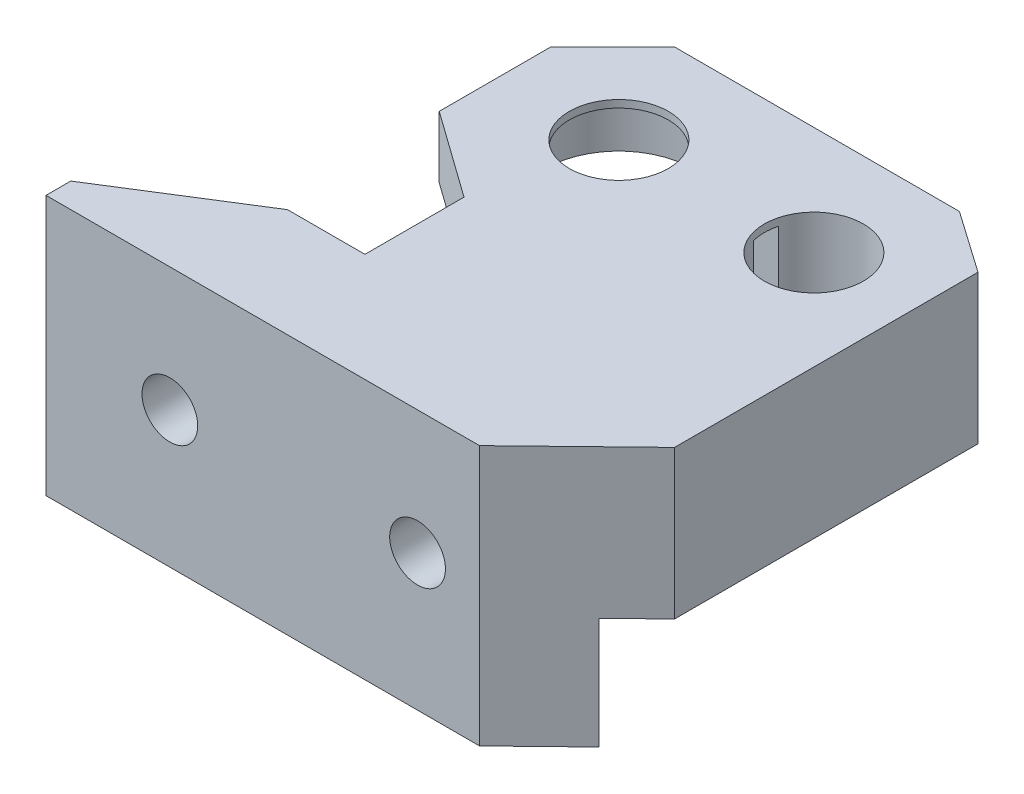
from build123d import *

# Parameters (mm, degrees)
SKETCH1_R           = 4
BOSS_EXTRUDE1_DEPTH = 5
BOSS_EXTRUDE2_DEPTH = 7
BOSS_EXTRUDE3_DEPTH = 16
SKETCH6_R           = 7
SKETCH6_R_2         = 4
BOSS_EXTRUDE4_DEPTH = 2.5
CUT_EXTRUDE1_DEPTH  = 4.4
CUT_EXTRUDE2_DEPTH  = 21.4
SKETCH8_R           = 2.25
CUT_EXTRUDE3_DEPTH  = 36.75
SKETCH9_R           = 4
CUT_EXTRUDE4_DEPTH  = 4


with BuildPart() as part:
    # Sketch1 → Boss-Extrude1 (new body)
    with BuildSketch(Plane(origin=(0, 0, 0), x_dir=(1, 0, 0), z_dir=(0, 1, 0))):
        Polygon((-4.25, 8.75), (18.75, 8.75), (23.75, 5.25), (23.75, -19.25), (15.75, -27), (-19.25, -27), (-19.25, -25), (-8.5, -18.25), (-2.25, -18.25), (-2.25, -10.25), (-9.25, -5.25), (-9.25, 3.75), align=None)
        Circle(SKETCH1_R, mode=Mode.SUBTRACT)
        with Locations((15.75, 0)):
            Circle(SKETCH1_R, mode=Mode.SUBTRACT)
    extrude(amount=BOSS_EXTRUDE1_DEPTH)

    # Sketch2 → Boss-Extrude2 (add)
    with BuildSketch(Plane.XZ):
        Polygon((23.75, 19.25), (23.75, -5.25), (20.25, -5.25), (20.25, 18.25), (-8.5, 18.25), (-14.87037037, 22.25), (20.653225806, 22.25), align=None)
    extrude(amount=BOSS_EXTRUDE2_DEPTH)

    # Sketch3 → Boss-Extrude3 (add)
    with BuildSketch(Plane.XZ):
        Polygon((-14.87037037, 22.25), (20.653225806, 22.25), (15.75, 27), (-19.25, 27), (-19.25, 25), align=None)
    extrude(amount=BOSS_EXTRUDE3_DEPTH)

    # Sketch6 → Boss-Extrude4 (add)
    with BuildSketch(Plane.XZ):
        with Locations((15.75, 0)):
            Circle(SKETCH6_R)
        with Locations((15.75, 0)):
            Circle(SKETCH6_R_2, mode=Mode.SUBTRACT)
    extrude(amount=BOSS_EXTRUDE4_DEPTH)

    # Sketch4 → Cut-Extrude1 (cut)
    with BuildSketch(Plane.XZ):
        with BuildLine():
            Line((5.883782294, -1), (12.395898034, -1))
            ThreePointArc((12.395898034, -1), (12.25, 0), (12.395898034, 1))
            Line((12.395898034, 1), (5.883782294, 1))
            ThreePointArc((5.883782294, 1), (-5.968156673, 0), (5.883782294, -1))
        make_face()
    extrude(amount=-CUT_EXTRUDE1_DEPTH, mode=Mode.SUBTRACT)

    # Sketch7 → Cut-Extrude2 (cut, through all)
    with BuildSketch(Plane.XZ.offset(-4.4)):
        with BuildLine():
            Line((5.883782294, -1), (11.877016654, -1))
            ThreePointArc((11.877016654, -1), (11.75, 0), (11.877016654, 1))
            Line((11.877016654, 1), (5.883782294, 1))
            ThreePointArc((5.883782294, 1), (-5.968156673, 0), (5.883782294, -1))
        make_face()
    extrude(amount=CUT_EXTRUDE2_DEPTH, mode=Mode.SUBTRACT)

    # Sketch8 → Cut-Extrude3 (cut, through all)
    with BuildSketch(Plane.XY.offset(27)):
        with Locations((10.75, -5)):
            Circle(SKETCH8_R)
        with Locations((-9.25, -5)):
            Circle(SKETCH8_R)
    extrude(amount=-CUT_EXTRUDE3_DEPTH, mode=Mode.SUBTRACT)

    # Sketch9 → Cut-Extrude4 (cut)
    with BuildSketch(Plane(origin=(0, 0, 18.25), x_dir=(-1, 0, 0), z_dir=(0, 0, -1))):
        with Locations((-10.75, -5)):
            Circle(SKETCH9_R)
        with Locations((9.25, -5)):
            Circle(SKETCH9_R)
    extrude(amount=-CUT_EXTRUDE4_DEPTH, mode=Mode.SUBTRACT)


solid = part.part
